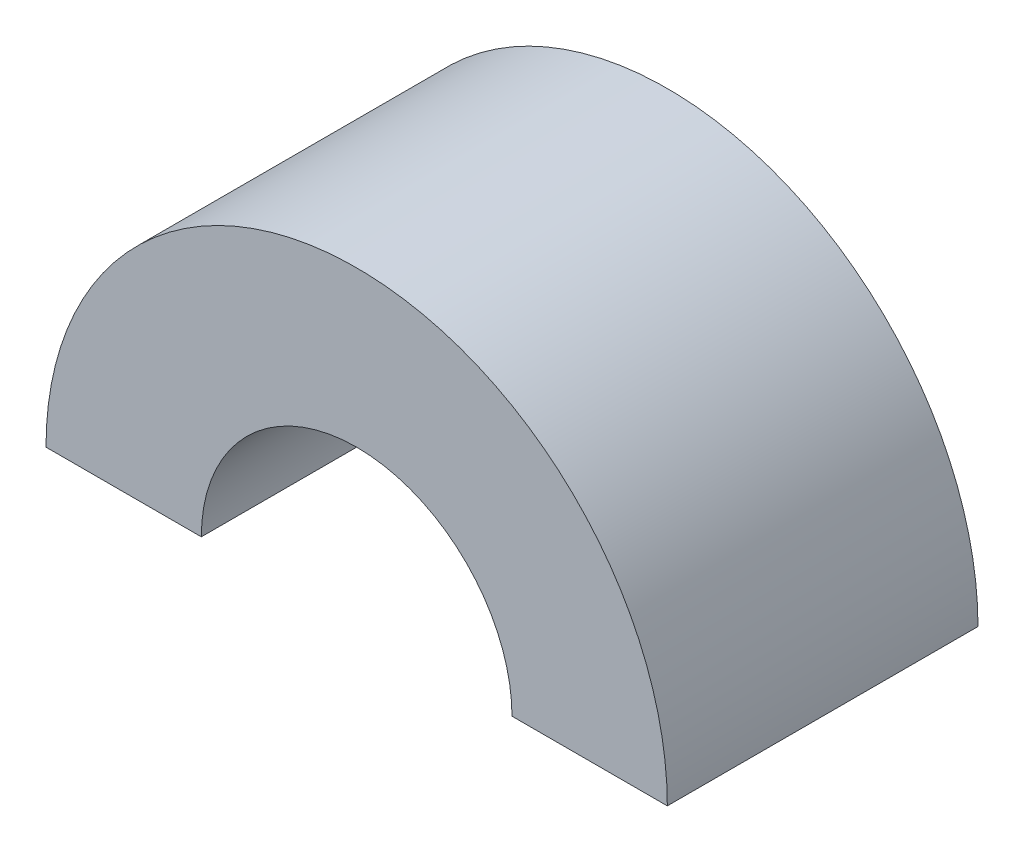
from build123d import *

# Parameters (mm, degrees)
BOSS_EXTRUDE1_DEPTH = 15


with BuildPart() as part:
    # Sketch1 → Boss-Extrude1 (new body)
    with BuildSketch(Plane.XY):
        with BuildLine():
            Line((-15, 0), (-7.5, 0))
            ThreePointArc((-7.5, 0), (0, 7.5), (7.5, 0))
            Line((7.5, 0), (15, 0))
            ThreePointArc((15, 0), (0, 15), (-15, 0))
        make_face()
    extrude(amount=BOSS_EXTRUDE1_DEPTH)


solid = part.part
